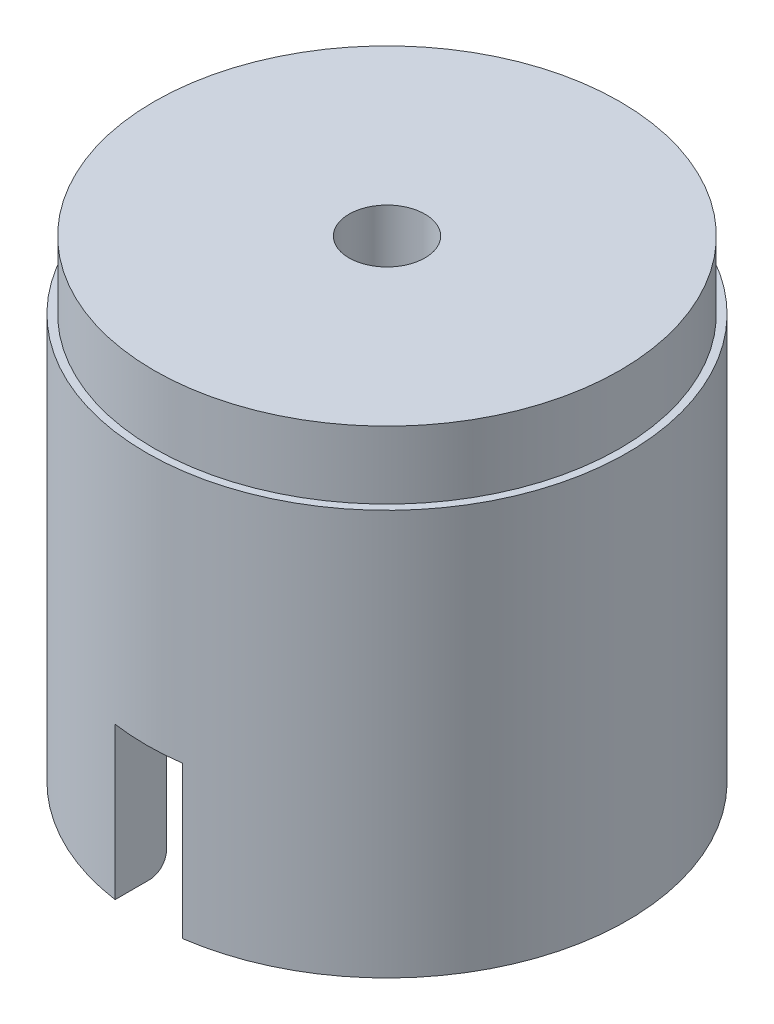
from build123d import *

# Parameters (mm, degrees)
SKETCH1_R           = 14.25
SKETCH1_R_2         = 11.25
BOSS_EXTRUDE1_DEPTH = 24
SKETCH2_R           = 13.8
SKETCH2_R_2         = 2.25
BOSS_EXTRUDE2_DEPTH = 4
FILLET1_R           = 1
CUT_EXTRUDE1_DEPTH  = 9


with BuildPart() as part:
    # Sketch1 → Boss-Extrude1 (new body)
    with BuildSketch(Plane(origin=(0, 0, 0), x_dir=(1, 0, 0), z_dir=(0, 1, 0))):
        Circle(SKETCH1_R)
        Circle(SKETCH1_R_2, mode=Mode.SUBTRACT)
    extrude(amount=BOSS_EXTRUDE1_DEPTH)

    # Sketch2 → Boss-Extrude2 (add)
    with BuildSketch(Plane(origin=(0, 24, 0), x_dir=(1, 0, 0), z_dir=(0, 1, 0))):
        Circle(SKETCH2_R)
        Circle(SKETCH2_R_2, mode=Mode.SUBTRACT)
    extrude(amount=BOSS_EXTRUDE2_DEPTH)

    # Fillet1
    fillet1_edges = [part.edges().sort_by_distance(p)[0] for p in [
        (-11.25, 0, 0),
    ]]
    fillet(fillet1_edges, radius=FILLET1_R)

    # Sketch3 → Cut-Extrude1 (cut)
    with BuildSketch(Plane.XZ):
        with BuildLine():
            Line((2, 14.25), (2, -14.25))
            ThreePointArc((2, -14.25), (0, -16.25), (-2, -14.25))
            Line((-2, -14.25), (-2, 14.25))
            ThreePointArc((-2, 14.25), (0, 16.25), (2, 14.25))
        make_face()
    extrude(amount=-CUT_EXTRUDE1_DEPTH, mode=Mode.SUBTRACT)


solid = part.part
